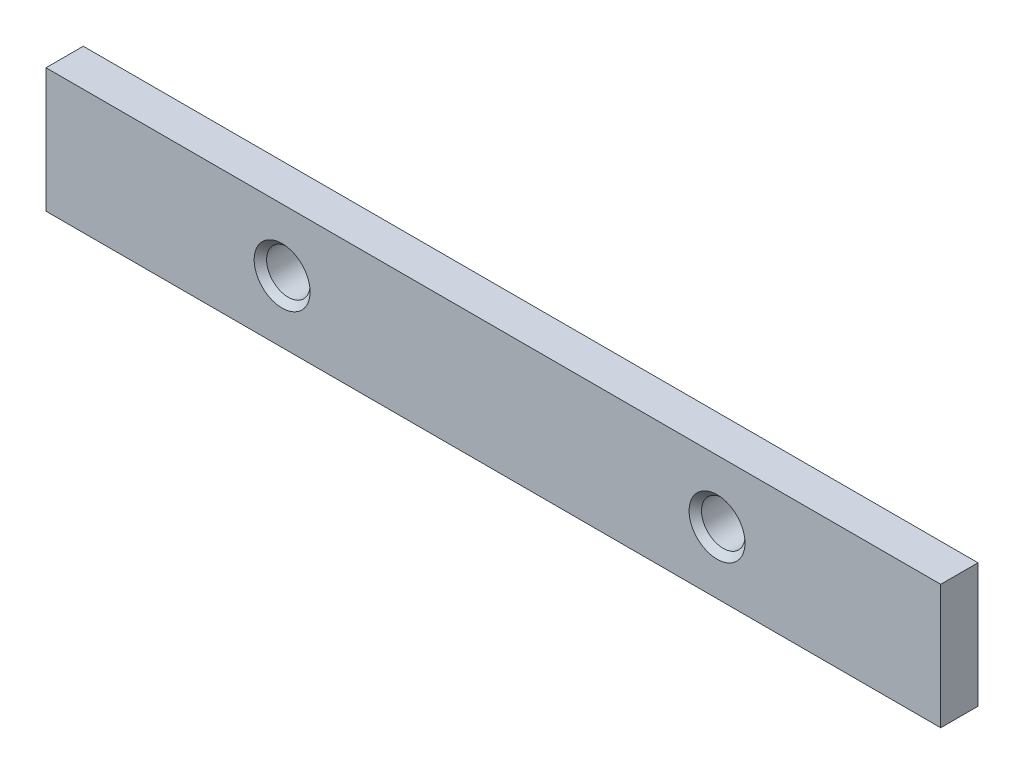
from build123d import *

# Parameters (mm, degrees)
SKETCH1_W                                            = 144
SKETCH1_H                                            = 20
BOSS_EXTRUDE1_DEPTH                                  = 6
CSK_FOR_M1_6_COUNTERSUNK_FLAT_HEAD_SCREW_D           = 7
CSK_FOR_M1_6_COUNTERSUNK_FLAT_HEAD_SCREW_CSINK_D     = 9
CSK_FOR_M1_6_COUNTERSUNK_FLAT_HEAD_SCREW_CSINK_ANGLE = 90


with BuildPart() as part:
    # Sketch1 → Boss-Extrude1 (new body)
    with BuildSketch(Plane.XY):
        Rectangle(SKETCH1_W, SKETCH1_H)
    extrude(amount=BOSS_EXTRUDE1_DEPTH)

    # CSK for M1.6 Countersunk Flat Head Screw1 (through all)
    with Locations(Plane.XY.offset(6)):
        with Locations((-34, 0), (36, 0)):
            CounterSinkHole(CSK_FOR_M1_6_COUNTERSUNK_FLAT_HEAD_SCREW_D / 2, CSK_FOR_M1_6_COUNTERSUNK_FLAT_HEAD_SCREW_CSINK_D / 2, counter_sink_angle=CSK_FOR_M1_6_COUNTERSUNK_FLAT_HEAD_SCREW_CSINK_ANGLE)


solid = part.part
